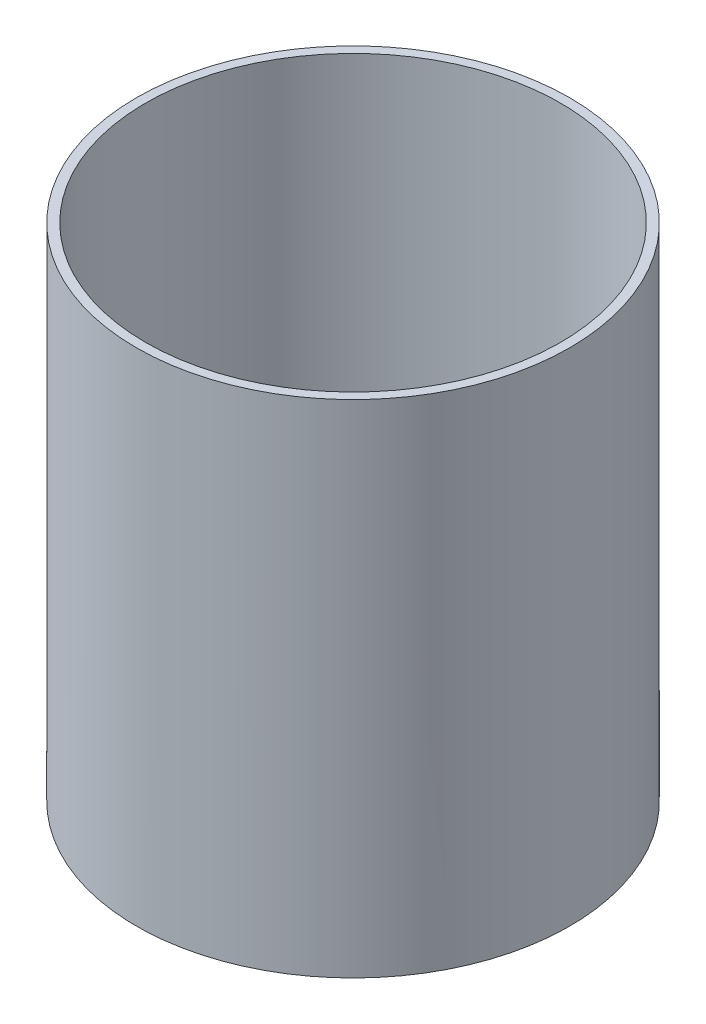
from build123d import *

# Parameters (mm, degrees)
SKETCH1_R           = 50.8
SKETCH1_R_2         = 48.641
BOSS_EXTRUDE1_DEPTH = 114.3
SKETCH2_R           = 50.8
SKETCH2_R_2         = 48.641
SKETCH2_R_3         = 3.175
BOSS_EXTRUDE2_DEPTH = 3.175


with BuildPart() as part:
    # Sketch1 → Boss-Extrude1 (new body)
    with BuildSketch(Plane(origin=(0, 0, 0), x_dir=(1, 0, 0), z_dir=(0, 1, 0))):
        with Locations(Location((0, 0, 0), (0, 0, 270))):
            Circle(SKETCH1_R)
        with Locations(Location((0, 0, 0), (0, 0, 270))):
            Circle(SKETCH1_R_2, mode=Mode.SUBTRACT)
    extrude(amount=BOSS_EXTRUDE1_DEPTH)

    # Sketch2 → Boss-Extrude2 (add)
    with BuildSketch(Plane.XZ):
        with Locations(Location((0, 0, 0), (0, 0, 270))):
            Circle(SKETCH2_R)
        with Locations(Location((0, 0, 0), (0, 0, 90))):
            Circle(SKETCH2_R_2, mode=Mode.SUBTRACT)
        with Locations(Location((0, 0, 0), (0, 0, 90))):
            Circle(SKETCH2_R_2)
        with Locations(Location((38.1, 0, 0), (0, 0, 270))):
            Circle(SKETCH2_R_3, mode=Mode.SUBTRACT)
        with Locations(Location((-38.1, 0, 0), (0, 0, 270))):
            Circle(SKETCH2_R_3, mode=Mode.SUBTRACT)
    extrude(amount=BOSS_EXTRUDE2_DEPTH)


solid = part.part
